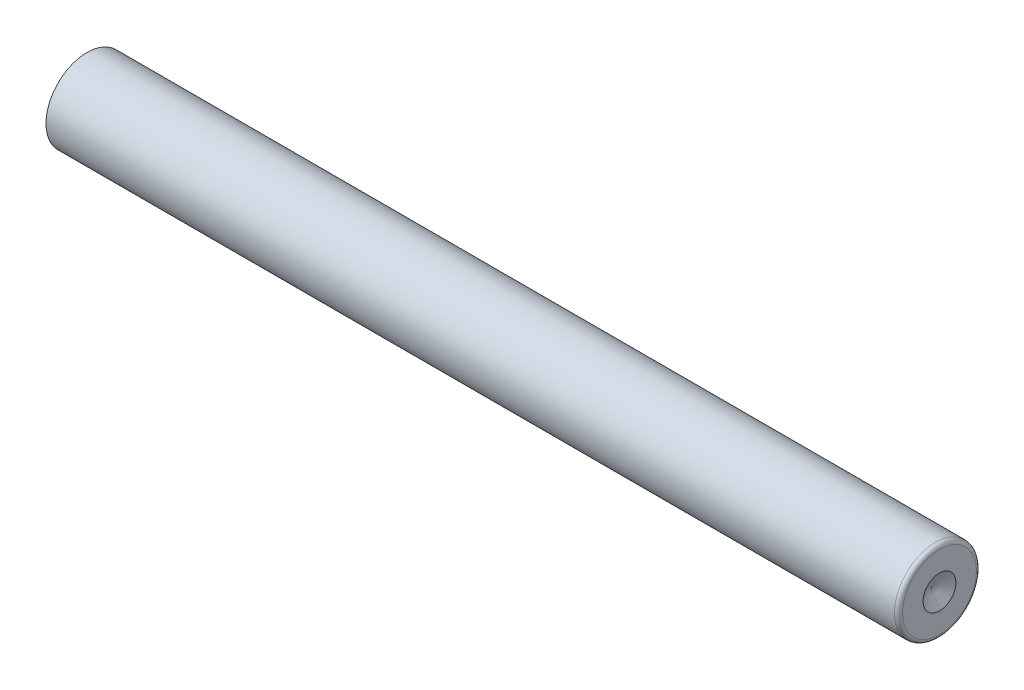
from build123d import *

# Parameters (mm, degrees)
CROQUIS1_W  = 52
CROQUIS1_H  = 2.5
REDONDEO1_R = 0.25


with BuildPart() as part:
    # Croquis1 → Revolución1 (revolve)
    with BuildSketch(Plane.XY):
        with Locations((26, 1.25)):
            Rectangle(CROQUIS1_W, CROQUIS1_H)
    revolve(axis=Axis((0, 0, 0), (1, 0, 0)))

    # Redondeo1
    redondeo1_edges = [part.edges().sort_by_distance(p)[0] for p in [
        (52, -2.5, 0),
    ]]
    fillet(redondeo1_edges, radius=REDONDEO1_R)

    # Croquis3 → Cortar-Revolución1 (revolve, cut)
    with BuildSketch(Plane.XY):
        Polygon((52, 0), (51.5, 0), (52, 1), align=None)
    revolve(axis=Axis((52, 0, 0), (-1, 0, 0)), mode=Mode.SUBTRACT)


solid = part.part
